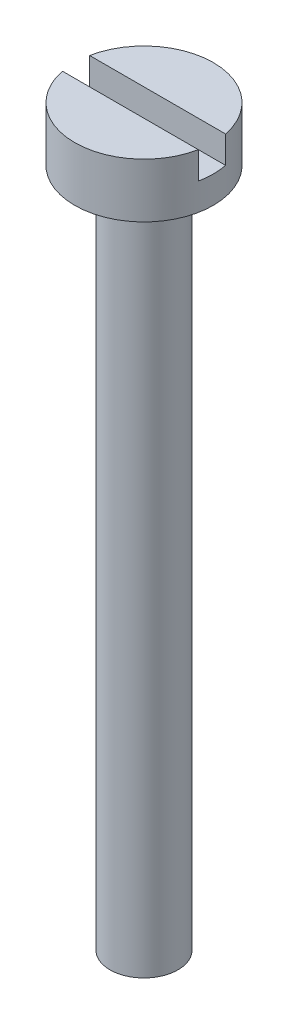
from build123d import *

# Parameters (mm, degrees)
SKETCH1_R           = 2.55
BOSS_EXTRUDE1_DEPTH = 2
SKETCH2_R           = 1.25
BOSS_EXTRUDE2_DEPTH = 25
SKETCH3_W           = 6
SKETCH3_H           = 1
CUT_EXTRUDE1_DEPTH  = 1


with BuildPart() as part:
    # Sketch1 → Boss-Extrude1 (new body)
    with BuildSketch(Plane(origin=(0, 0, 0), x_dir=(1, 0, 0), z_dir=(0, 1, 0))):
        Circle(SKETCH1_R)
    extrude(amount=BOSS_EXTRUDE1_DEPTH)

    # Sketch2 → Boss-Extrude2 (add)
    with BuildSketch(Plane(origin=(0, 0, 0), x_dir=(1, 0, 0), z_dir=(0, 1, 0))):
        Circle(SKETCH2_R)
    extrude(amount=-BOSS_EXTRUDE2_DEPTH)

    # Sketch3 → Cut-Extrude1 (cut)
    with BuildSketch(Plane(origin=(0, 2, 0), x_dir=(1, 0, 0), z_dir=(0, 1, 0))):
        Rectangle(SKETCH3_W, SKETCH3_H)
    extrude(amount=-CUT_EXTRUDE1_DEPTH, mode=Mode.SUBTRACT)


solid = part.part
